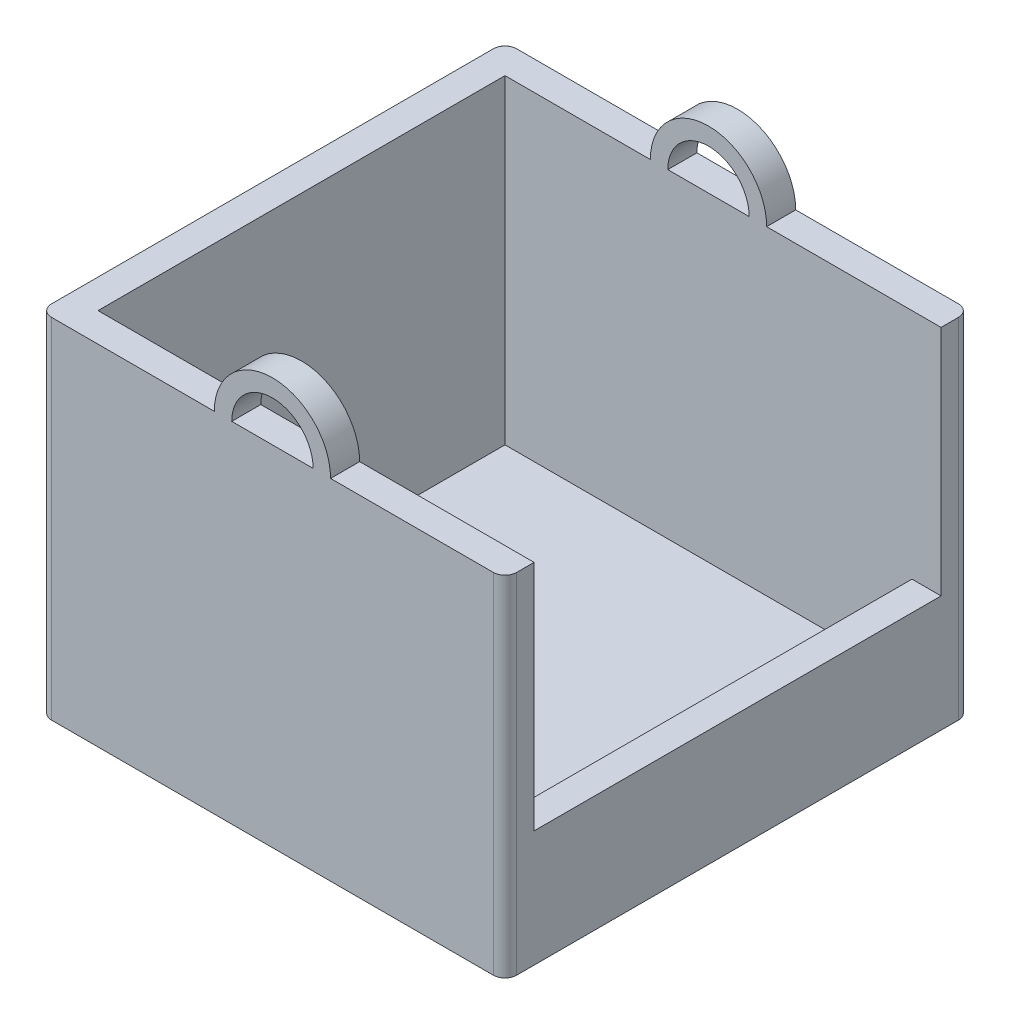
from build123d import *

# Parameters (mm, degrees)
SKETCH1_W           = 40
SKETCH1_H           = 40
SKETCH1_W_2         = 35
SKETCH1_H_2         = 35
BOSS_EXTRUDE1_DEPTH = 30
SKETCH2_W           = 40
SKETCH2_H           = 40
BOSS_EXTRUDE2_DEPTH = 2.5
SKETCH3_W           = 35
SKETCH3_H           = 20
CUT_EXTRUDE1_DEPTH  = 2.5
FILLET1_R           = 1
FILLET2_R           = 1
BOSS_EXTRUDE3_DEPTH = 2.5
BOSS_EXTRUDE4_DEPTH = 2.5


with BuildPart() as part:
    # Sketch1 → Boss-Extrude1 (new body)
    with BuildSketch(Plane(origin=(0, 0, 0), x_dir=(1, 0, 0), z_dir=(0, 1, 0))):
        Rectangle(SKETCH1_W, SKETCH1_H)
        Rectangle(SKETCH1_W_2, SKETCH1_H_2, mode=Mode.SUBTRACT)
    extrude(amount=BOSS_EXTRUDE1_DEPTH)

    # Sketch2 → Boss-Extrude2 (add)
    with BuildSketch(Plane(origin=(0, 0, 0), x_dir=(1, 0, 0), z_dir=(0, 1, 0))):
        Rectangle(SKETCH2_W, SKETCH2_H)
    extrude(amount=BOSS_EXTRUDE2_DEPTH)

    # Sketch3 → Cut-Extrude1 (cut)
    with BuildSketch(Plane(origin=(20, 0, 0), x_dir=(0, 0, -1), z_dir=(1, 0, 0))):
        with Locations((0, 20)):
            Rectangle(SKETCH3_W, SKETCH3_H)
    extrude(amount=-CUT_EXTRUDE1_DEPTH, mode=Mode.SUBTRACT)

    # Fillet1
    fillet1_edges = [part.edges().sort_by_distance(p)[0] for p in [
        (20, 15, 20),
        (-20, 15, 20),
    ]]
    fillet(fillet1_edges, radius=FILLET1_R)

    # Fillet2
    fillet2_edges = [part.edges().sort_by_distance(p)[0] for p in [
        (-20, 15, -20),
        (20, 15, -20),
    ]]
    fillet(fillet2_edges, radius=FILLET2_R)

    # Sketch4 → Boss-Extrude3 (add)
    with BuildSketch(Plane.XY.offset(20)):
        with BuildLine():
            ThreePointArc((-3.5, 30), (-2.474873734, 32.474873734), (0, 33.5))
            Line((0, 33.5), (0, 35))
            ThreePointArc((0, 35), (-3.535533906, 33.535533906), (-5, 30))
            Line((-5, 30), (-3.5, 30))
        make_face()
        with BuildLine():
            Line((0, 35), (0, 33.5))
            ThreePointArc((0, 33.5), (2.474873734, 32.474873734), (3.5, 30))
            Line((3.5, 30), (5, 30))
            ThreePointArc((5, 30), (3.535533906, 33.535533906), (0, 35))
        make_face()
    extrude(amount=-BOSS_EXTRUDE3_DEPTH)

    # Sketch5 → Boss-Extrude4 (add)
    with BuildSketch(Plane(origin=(0, 0, -20), x_dir=(-1, 0, 0), z_dir=(0, 0, -1))):
        with BuildLine():
            ThreePointArc((-3.5, 30), (-2.474873734, 32.474873734), (0, 33.5))
            Line((0, 33.5), (0, 35))
            ThreePointArc((0, 35), (-3.535533906, 33.535533906), (-5, 30))
            Line((-5, 30), (-3.5, 30))
        make_face()
        with BuildLine():
            Line((0, 35), (0, 33.5))
            ThreePointArc((0, 33.5), (2.474873734, 32.474873734), (3.5, 30))
            Line((3.5, 30), (5, 30))
            ThreePointArc((5, 30), (3.535533906, 33.535533906), (0, 35))
        make_face()
    extrude(amount=-BOSS_EXTRUDE4_DEPTH)


solid = part.part
